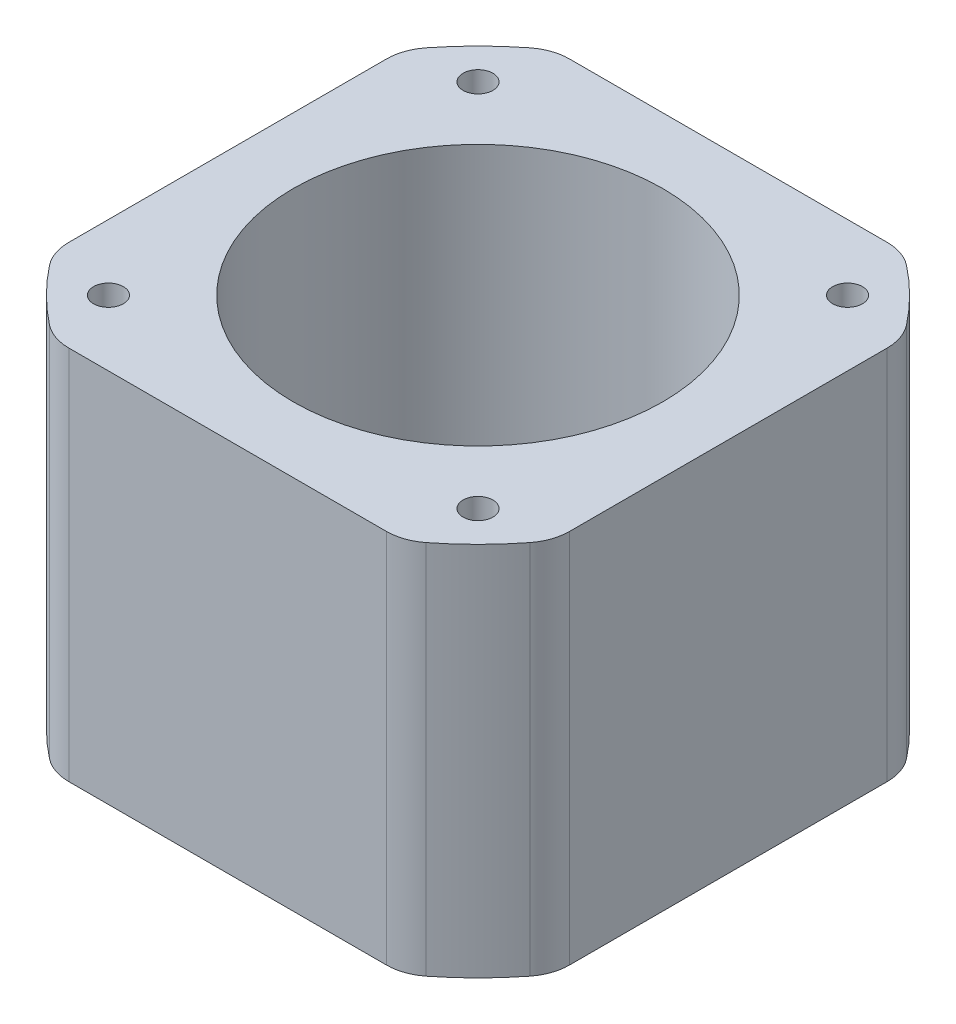
from build123d import *

# Parameters (mm, degrees)
SKETCH_1_R      = 1.25
SKETCH_1_R_2    = 15.5
EXTRUDE_1_DEPTH = 31.5
FILLET_1_R      = 4


with BuildPart() as part:
    # Эскиз1 → Бобышка-Вытянуть1 (new body)
    with BuildSketch(Plane(origin=(0, 0, 0), x_dir=(1, 0, 0), z_dir=(0, 1, 0))):
        with BuildLine():
            Line((-14.641038215, -21), (14.641038215, -21))
            ThreePointArc((14.641038215, -21), (18.101933598, -18.101933598), (21, -14.641038215))
            Line((21, -14.641038215), (21, 14.641038215))
            ThreePointArc((21, 14.641038215), (18.101933598, 18.101933598), (14.641038215, 21))
            Line((14.641038215, 21), (-14.641038215, 21))
            ThreePointArc((-14.641038215, 21), (-18.101933598, 18.101933598), (-21, 14.641038215))
            Line((-21, 14.641038215), (-21, -14.641038215))
            ThreePointArc((-21, -14.641038215), (-18.101933598, -18.101933598), (-14.641038215, -21))
        make_face()
        with Locations((-15.5, 15.5)):
            Circle(SKETCH_1_R, mode=Mode.SUBTRACT)
        with Locations((15.5, 15.5)):
            Circle(SKETCH_1_R, mode=Mode.SUBTRACT)
        with Locations((15.5, -15.5)):
            Circle(SKETCH_1_R, mode=Mode.SUBTRACT)
        with Locations((-15.5, -15.5)):
            Circle(SKETCH_1_R, mode=Mode.SUBTRACT)
        Circle(SKETCH_1_R_2, mode=Mode.SUBTRACT)
    extrude(amount=EXTRUDE_1_DEPTH)

    # Скругление1
    fillet_1_edges = [part.edges().sort_by_distance(p)[0] for p in [
        (21, 15.75, -14.641038215),
        (21, 15.75, 14.641038215),
        (14.641038215, 15.75, 21),
        (-14.641038215, 15.75, 21),
        (-21, 15.75, 14.641038215),
        (-21, 15.75, -14.641038215),
        (-14.641038215, 15.75, -21),
        (14.641038215, 15.75, -21),
    ]]
    fillet(fillet_1_edges, radius=FILLET_1_R)


solid = part.part
